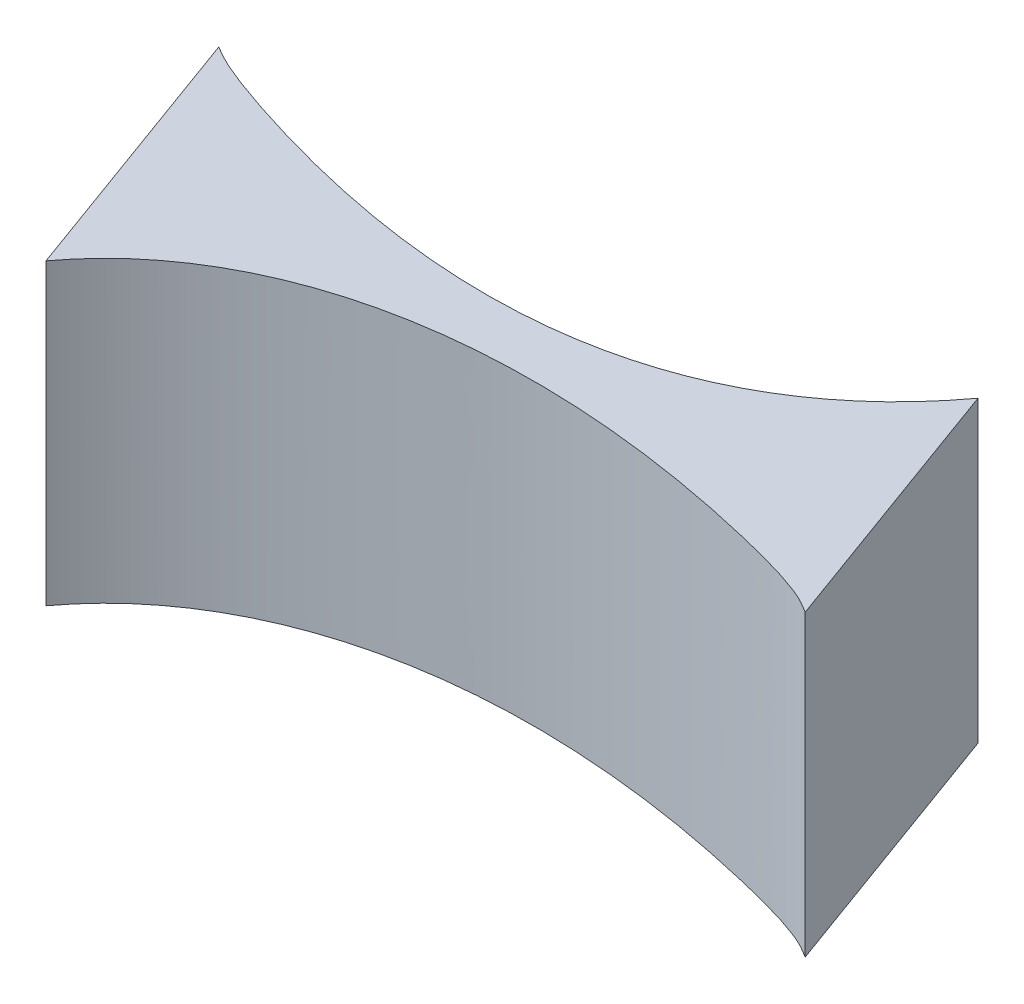
from build123d import *

# Parameters (mm, degrees)
BOSS_EXTRUDE1_DEPTH = 31


with BuildPart() as part:
    # Sketch1 → Boss-Extrude1 (new body)
    with BuildSketch(Plane(origin=(0, 0, 0), x_dir=(1, 0, 0), z_dir=(0, 1, 0))):
        with BuildLine():
            Line((-4.716280072, -52.391044588), (-14.97688437, -24.20026596))
            add(Edge.make_bspline(
                [(55.99141165, -16.37494241), (45.958907143, -30.008858792), (25.194080199, -38.922897686), (-12.760591176, -25.602765697), (-14.605421945, -24.411818747), (-14.97688437, -24.20026596)],
                knots=[0, 0, 0, 0, 0.403451926, 0.449136909, 0.456849828, 0.456849828, 0.456849828, 0.456849828], degree=3))
            Line((55.99141165, -16.37494241), (66.25201595, -44.565721037))
            add(Edge.make_bspline(
                [(-4.716280072, -52.391044588), (5.316224436, -38.757128206), (29.941795264, -33.55471635), (63.936743914, -43.068065403), (65.880553525, -44.354168251), (66.25201595, -44.565721037)],
                knots=[0, 0, 0, 0, 0.403451926, 0.449136909, 0.456849828, 0.456849828, 0.456849828, 0.456849828], degree=3))
        make_face()
    extrude(amount=BOSS_EXTRUDE1_DEPTH)


solid = part.part
